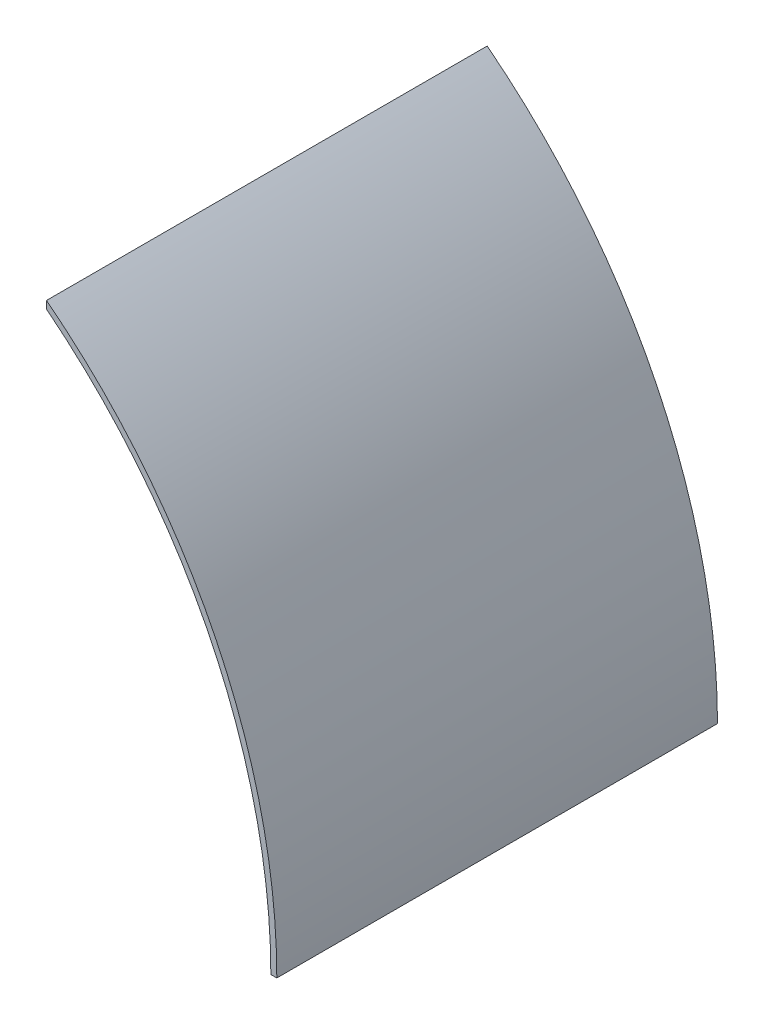
from build123d import *

# Parameters (mm, degrees)
INNER_RING_RIGHT_SIDE_DEPTH = 112.268


with BuildPart() as part:
    # Sketch2 → Inner Ring - Right Side (new body)
    with BuildSketch(Plane.XY):
        with BuildLine():
            Line((93.73108, 120.167569011), (93.73108, 118.235294832))
            ThreePointArc((93.73108, 118.235294832), (135.844298522, 65.661456434), (150.88108, 0))
            Line((150.88108, 0), (152.4, 0))
            ThreePointArc((152.4, 0), (136.949583044, 66.862333971), (93.73108, 120.167569011))
        make_face()
    extrude(amount=INNER_RING_RIGHT_SIDE_DEPTH)


solid = part.part
